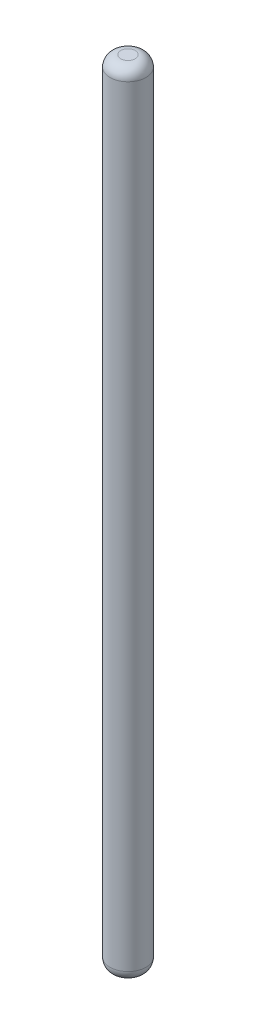
from build123d import *

# Parameters (mm, degrees)
SKETCH1_R           = 2.5
BOSS_EXTRUDE1_DEPTH = 110
FILLET1_R           = 1.5


with BuildPart() as part:
    # Sketch1 → Boss-Extrude1 (new body)
    with BuildSketch(Plane(origin=(0, 0, 0), x_dir=(1, 0, 0), z_dir=(0, 1, 0))):
        Circle(SKETCH1_R)
    extrude(amount=BOSS_EXTRUDE1_DEPTH)

    # Fillet1
    fillet1_edges = [part.edges().sort_by_distance(p)[0] for p in [
        (-2.5, 0, 0),
        (-2.5, 110, 0),
    ]]
    fillet(fillet1_edges, radius=FILLET1_R)


solid = part.part
